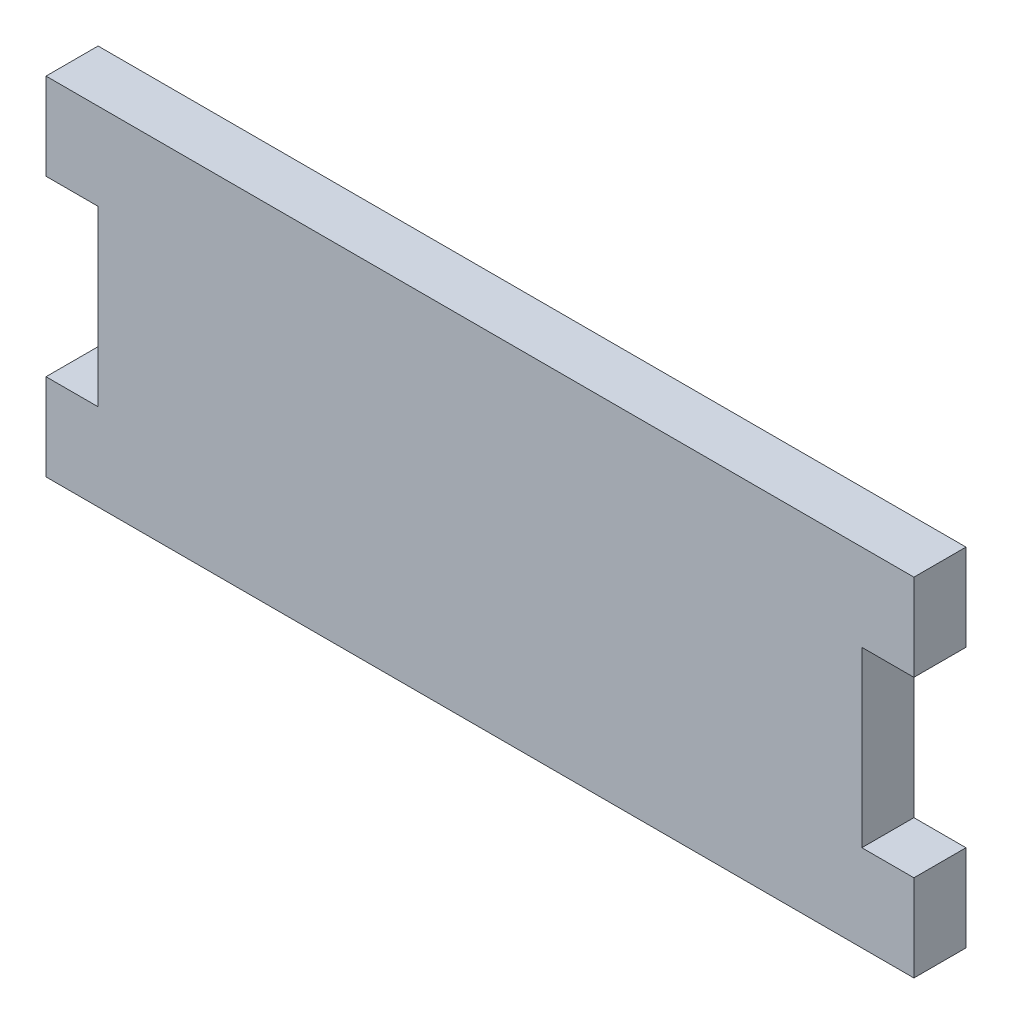
from build123d import *

# Parameters (mm, degrees)
SALIENTE_EXTRUIR1_DEPTH = 3


with BuildPart() as part:
    # Model → Saliente-Extruir1 (new body)
    with BuildSketch(Plane.XY):
        Polygon((46.261568, 3.564832), (-3.738432, 3.564832), (-3.738432, 8.564832), (-0.738432, 8.564832), (-0.738432, 18.564832), (-3.738432, 18.564832), (-3.738432, 23.564832), (46.261568, 23.564832), (46.261568, 18.564832), (43.261568, 18.564832), (43.261568, 8.564832), (46.261568, 8.564832), align=None)
    extrude(amount=SALIENTE_EXTRUIR1_DEPTH)


solid = part.part
